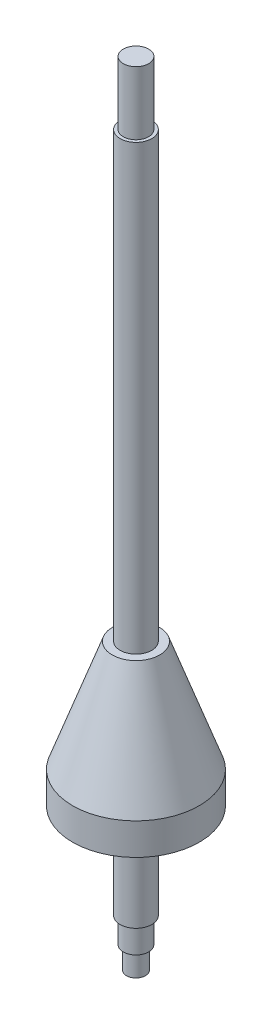
from build123d import *


with BuildPart() as part:
    # Sketch1 → Revolve3 (revolve)
    with BuildSketch(Plane.XY, mode=Mode.PRIVATE) as revolve3_sk:
        Polygon((10, 0), (20, 0), (20, 10), (7.5, 45), (5, 45), (5, 185), (4, 185), (4, 205), (0, 205), (0, -45), (3, -45), (3, -38), (4, -38), (4, -30), (5, -30), (5, -5), (10, -5), align=None)
    revolve(revolve3_sk.sketch.rotate(Axis((0, 266.57973029, 0), (0, -1, 0)), 90), axis=Axis((0, 266.57973029, 0), (0, -1, 0)))  # turned: the seam where the file's is


solid = part.part
